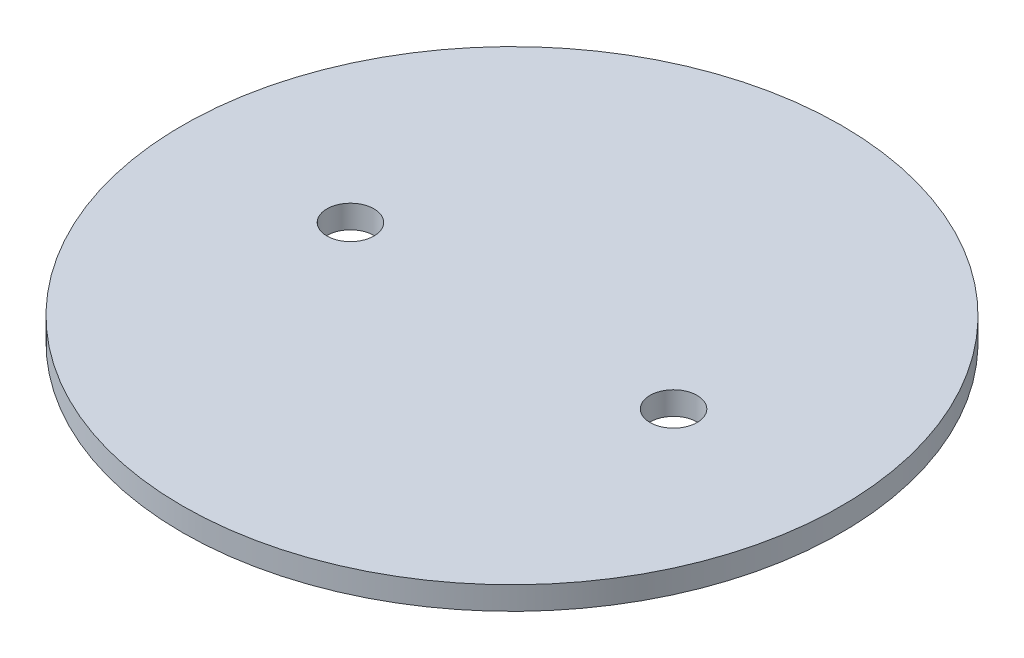
from build123d import *

# Parameters (mm, degrees)
SKETCH1_R           = 45.339
SKETCH1_R_2         = 3.2385
BOSS_EXTRUDE1_DEPTH = 3.175


with BuildPart() as part:
    # Sketch1 → Boss-Extrude1 (new body)
    with BuildSketch(Plane(origin=(0, 0, 0), x_dir=(1, 0, 0), z_dir=(0, 1, 0))):
        Circle(SKETCH1_R)
        with Locations((22.225, 0)):
            Circle(SKETCH1_R_2, mode=Mode.SUBTRACT)
        with Locations((-22.225, 0)):
            Circle(SKETCH1_R_2, mode=Mode.SUBTRACT)
    extrude(amount=BOSS_EXTRUDE1_DEPTH)


solid = part.part
